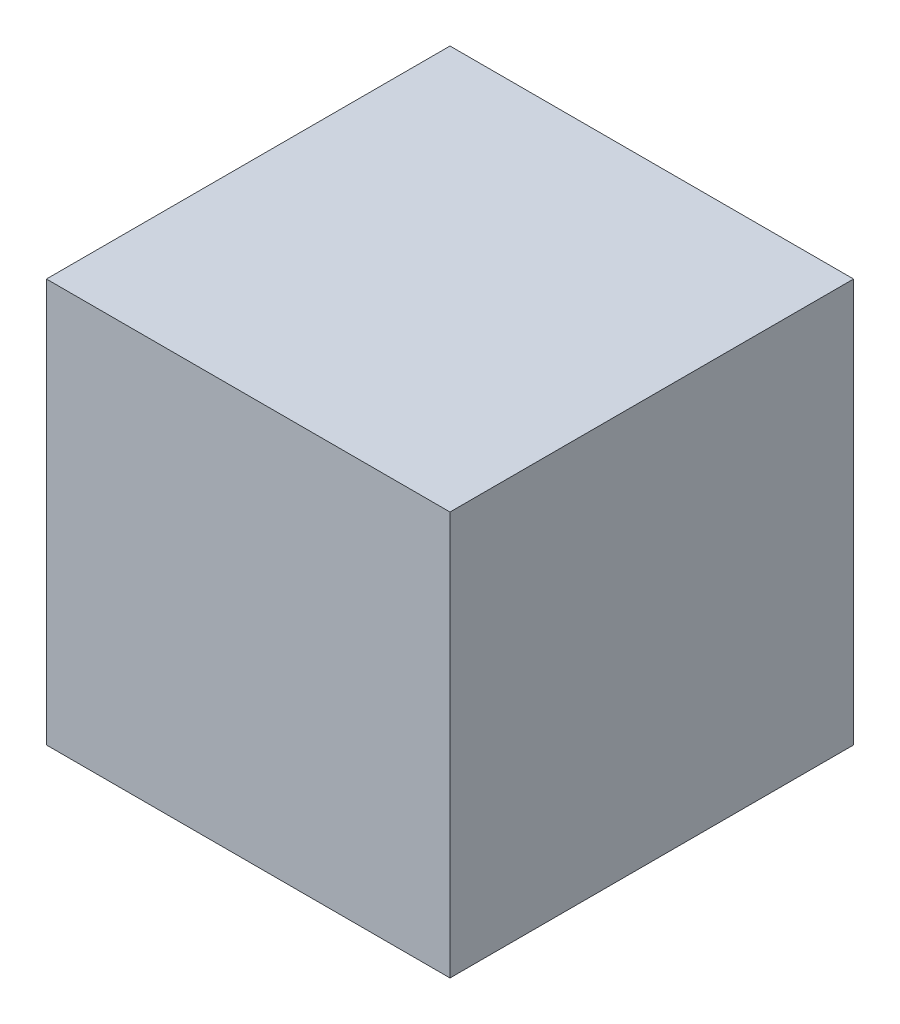
from build123d import *

# Parameters (mm, degrees)
SKETCH1_W           = 30
SKETCH1_H           = 30
BOSS_EXTRUDE1_DEPTH = 30


with BuildPart() as part:
    # Sketch1 → Boss-Extrude1 (new body)
    with BuildSketch(Plane.XY):
        with Locations((-5.948597436, 10.035303498)):
            Rectangle(SKETCH1_W, SKETCH1_H)
    extrude(amount=BOSS_EXTRUDE1_DEPTH)


solid = part.part
